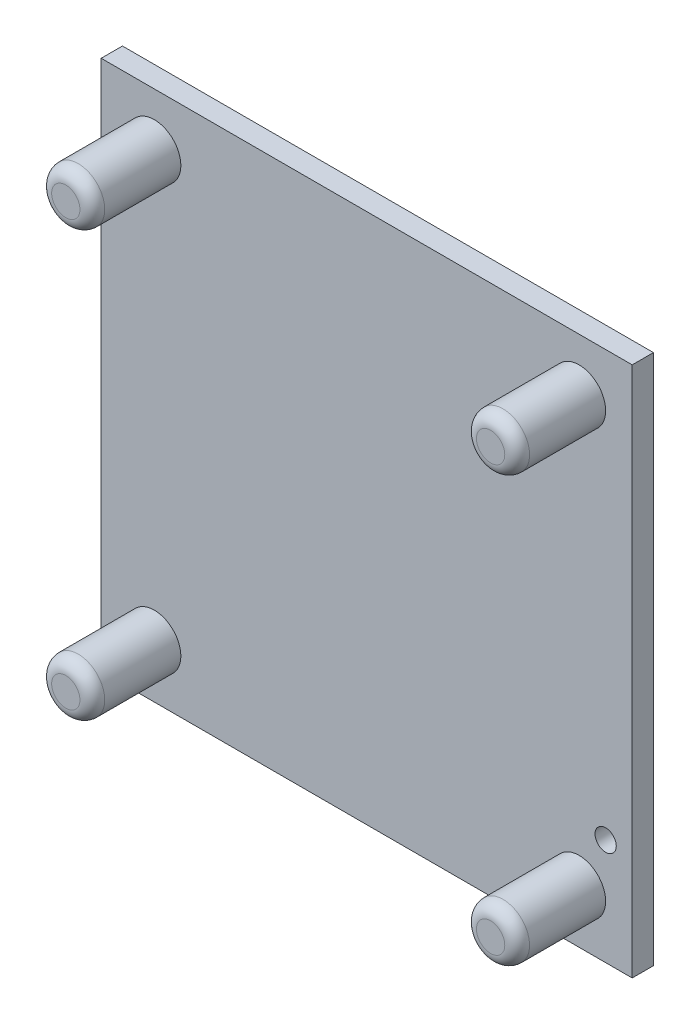
from build123d import *

# Parameters (mm, degrees)
SKETCH2_W                  = 300
SKETCH2_H                  = 300
BOSS_EXTRUDE1_DEPTH        = 12
SKETCH3_R                  = 15
BOSS_EXTRUDE2_DEPTH        = 50
FILLET1_R                  = 7
F_12_0_12_DIAMETER_HOLE1_D = 12


with BuildPart() as part:
    # Sketch2 → Boss-Extrude1 (new body)
    with BuildSketch(Plane.XY):
        Rectangle(SKETCH2_W, SKETCH2_H)
    extrude(amount=BOSS_EXTRUDE1_DEPTH)

    # Sketch3 → Boss-Extrude2 (add)
    with BuildSketch(Plane.XY.offset(12)):
        with Locations((120, -120)):
            Circle(SKETCH3_R)
        with Locations((-120, -120)):
            Circle(SKETCH3_R)
        with Locations((-120, 120)):
            Circle(SKETCH3_R)
        with Locations((120, 120)):
            Circle(SKETCH3_R)
    extrude(amount=BOSS_EXTRUDE2_DEPTH)

    # Fillet1
    fillet1_edges = [part.edges().sort_by_distance(p)[0] for p in [
        (-135, -120, 62),
        (105, -120, 62),
        (-135, 120, 62),
        (105, 120, 62),
    ]]
    fillet(fillet1_edges, radius=FILLET1_R)

    # Ø12.0 (12) Diameter Hole1 (through all)
    with Locations(Plane.XY.offset(12)):
        with Locations((135, -90)):
            Hole(F_12_0_12_DIAMETER_HOLE1_D / 2)


solid = part.part
